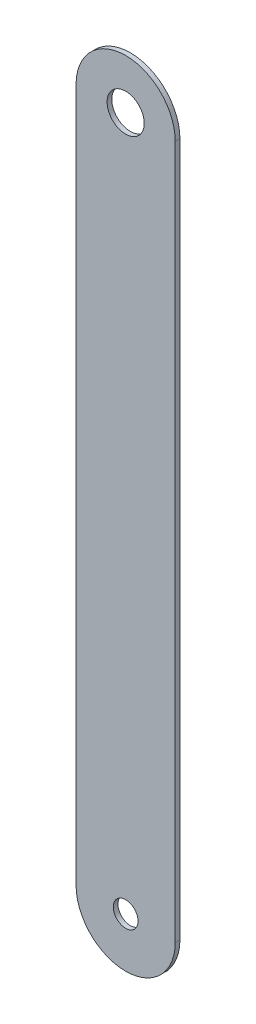
from build123d import *

# Parameters (mm, degrees)
SKETCH1_R           = 4.7625
SKETCH1_R_2         = 3.175
BOSS_EXTRUDE1_DEPTH = 1.2


with BuildPart() as part:
    # Sketch1 → Boss-Extrude1 (new body)
    with BuildSketch(Plane.XY):
        with BuildLine():
            Line((-12.7, 88.9), (-12.7, -88.9))
            ThreePointArc((-12.7, -88.9), (0, -101.6), (12.7, -88.9))
            Line((12.7, -88.9), (12.7, 88.9))
            ThreePointArc((12.7, 88.9), (0, 101.6), (-12.7, 88.9))
        make_face()
        with Locations((0, 88.9)):
            Circle(SKETCH1_R, mode=Mode.SUBTRACT)
        with Locations((0, -88.9)):
            Circle(SKETCH1_R_2, mode=Mode.SUBTRACT)
    extrude(amount=BOSS_EXTRUDE1_DEPTH)


solid = part.part
